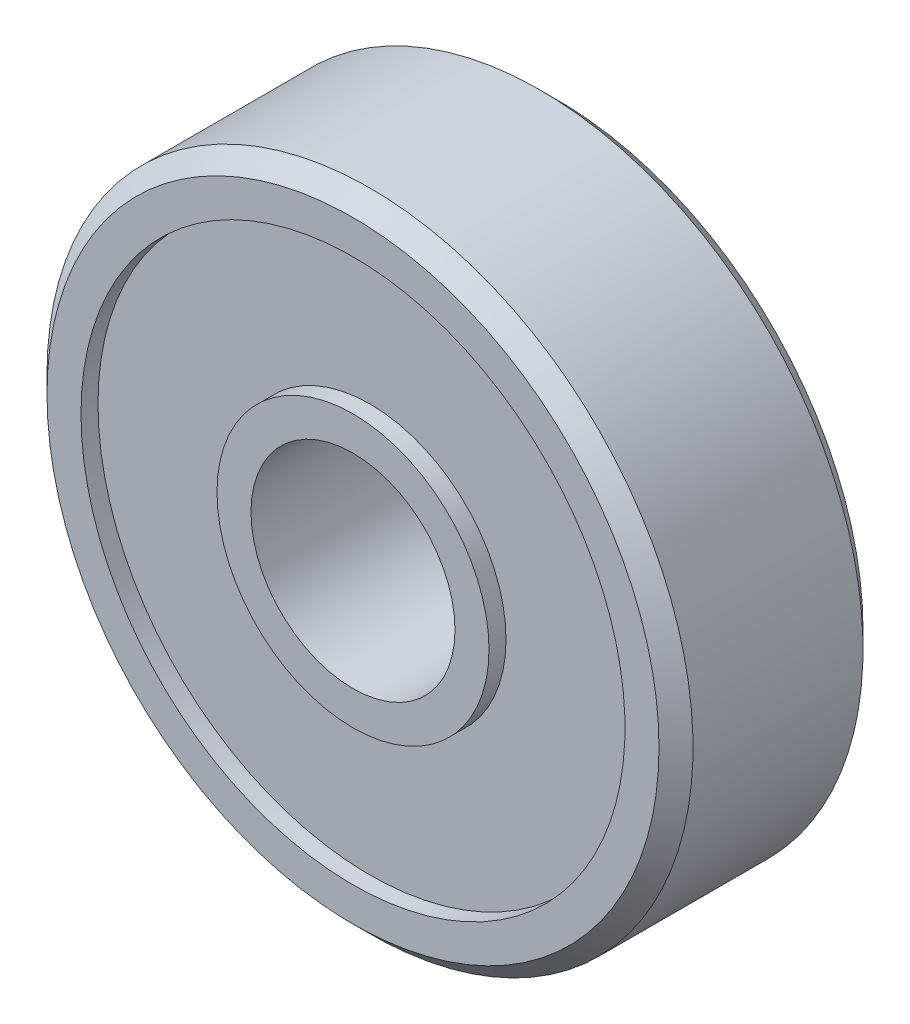
from build123d import *


with BuildPart() as part:
    # Sketch1 → Revolve1 (revolve)
    with BuildSketch(Plane.XZ):
        Polygon((9.5, 1), (9, 1.5), (8, 1.5), (8, 1), (4, 1), (4, 1.5), (3, 1.5), (3, -4.5), (4, -4.5), (4, -4), (8, -4), (8, -4.5), (9, -4.5), (9.5, -4), align=None)
    revolve(axis=Axis((0, 0, 0.5), (0, 0, -1)))


solid = part.part
